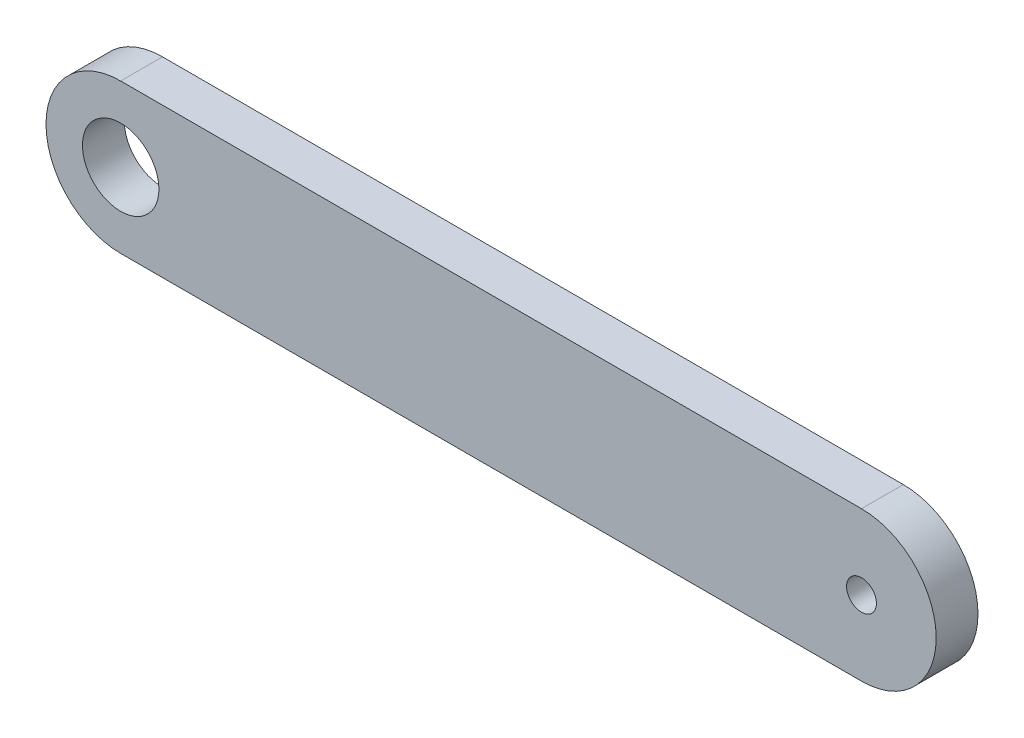
from build123d import *

# Parameters (mm, degrees)
SKETCH1_R           = 1.6
SKETCH1_R_2         = 0.625
BOSS_EXTRUDE1_DEPTH = 1.75


with BuildPart() as part:
    # Sketch1 → Boss-Extrude1 (new body)
    with BuildSketch(Plane.XY):
        with BuildLine():
            Line((0, 3.125), (31, 3.125))
            ThreePointArc((31, 3.125), (34.125, 0), (31, -3.125))
            Line((31, -3.125), (0, -3.125))
            ThreePointArc((0, -3.125), (-3.125, 0), (0, 3.125))
        make_face()
        Circle(SKETCH1_R, mode=Mode.SUBTRACT)
        with Locations((31, 0)):
            Circle(SKETCH1_R_2, mode=Mode.SUBTRACT)
    extrude(amount=BOSS_EXTRUDE1_DEPTH)


solid = part.part
